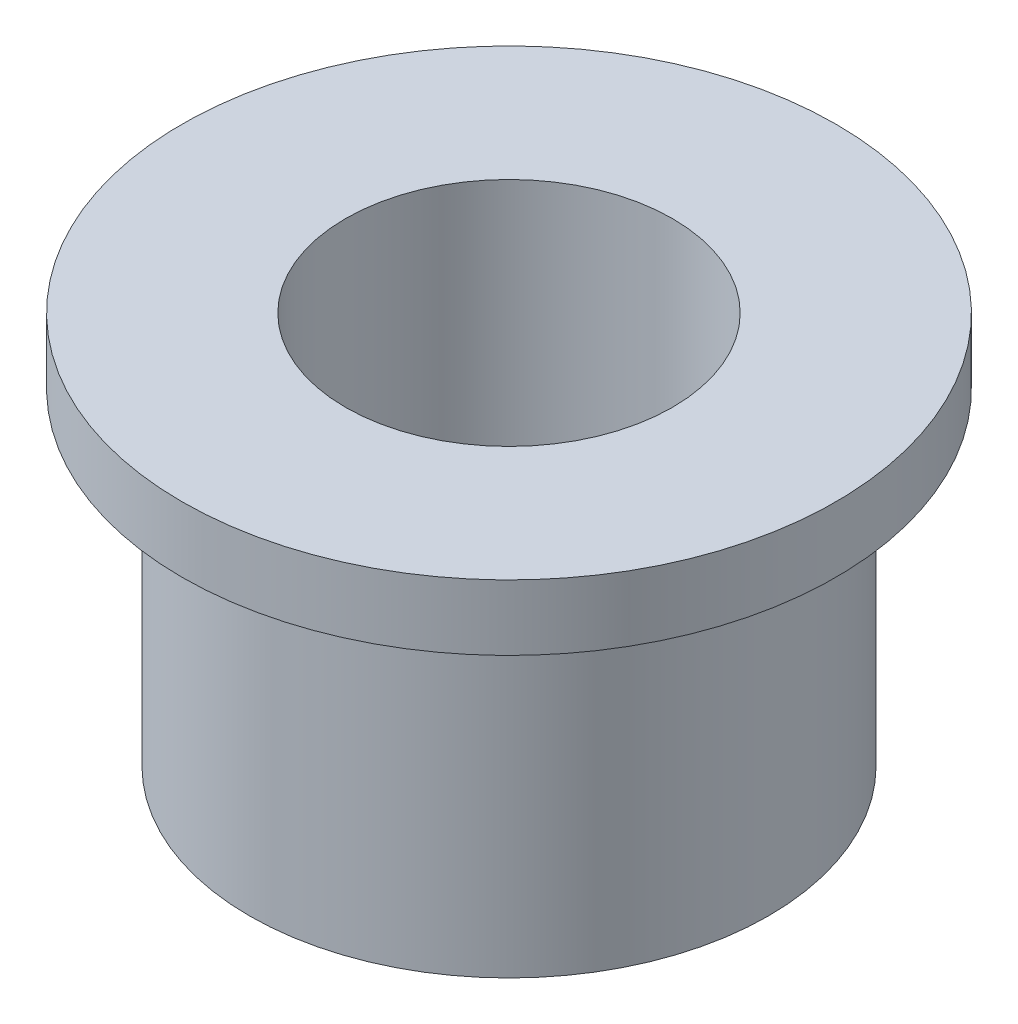
from build123d import *


with BuildPart() as part:
    # Sketch1 → Revolve1 (revolve)
    with BuildSketch(Plane.XY):
        Polygon((5, 1.032258065), (5, -10.967741935), (7.9375, -10.967741935), (7.9375, -0.967741935), (10, -0.967741935), (10, 1.032258065), align=None)
    revolve(axis=Axis((0, 0, 0), (0, -1, 0)))


solid = part.part
